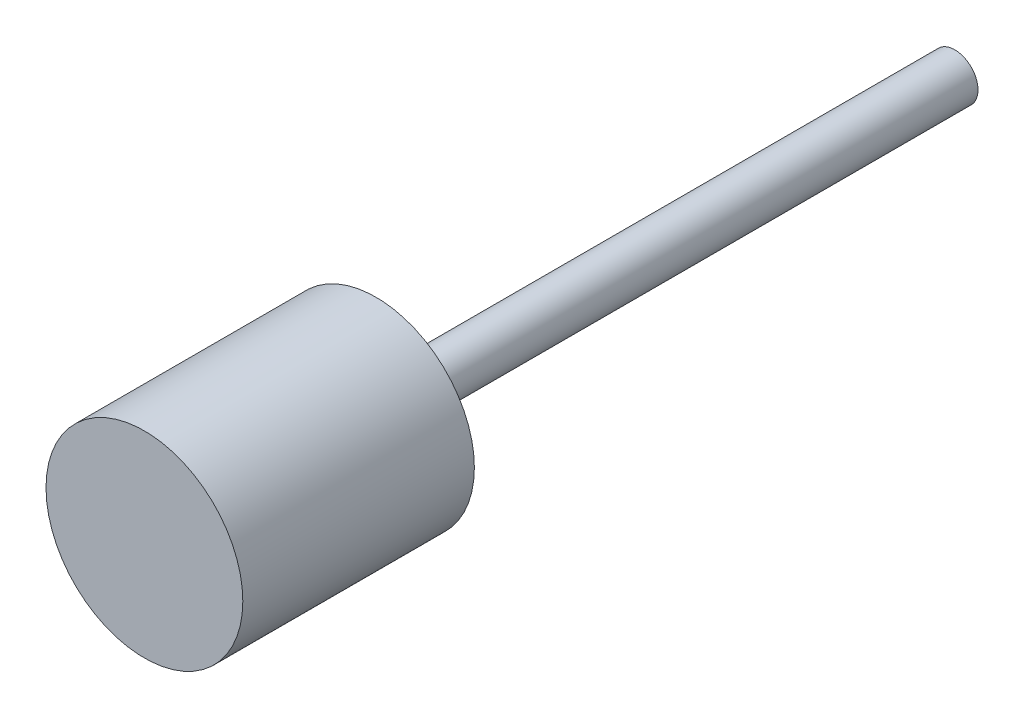
from build123d import *

# Parameters (mm, degrees)
SKETCH1_R           = 2
BOSS_EXTRUDE1_DEPTH = 50
SKETCH2_R           = 8.5
BOSS_EXTRUDE2_DEPTH = 20


with BuildPart() as part:
    # Sketch1 → Boss-Extrude1 (new body)
    with BuildSketch(Plane.XY):
        Circle(SKETCH1_R)
    extrude(amount=BOSS_EXTRUDE1_DEPTH)

    # Sketch2 → Boss-Extrude2 (add)
    with BuildSketch(Plane.XY.offset(50)):
        Circle(SKETCH2_R)
    extrude(amount=BOSS_EXTRUDE2_DEPTH)


solid = part.part
